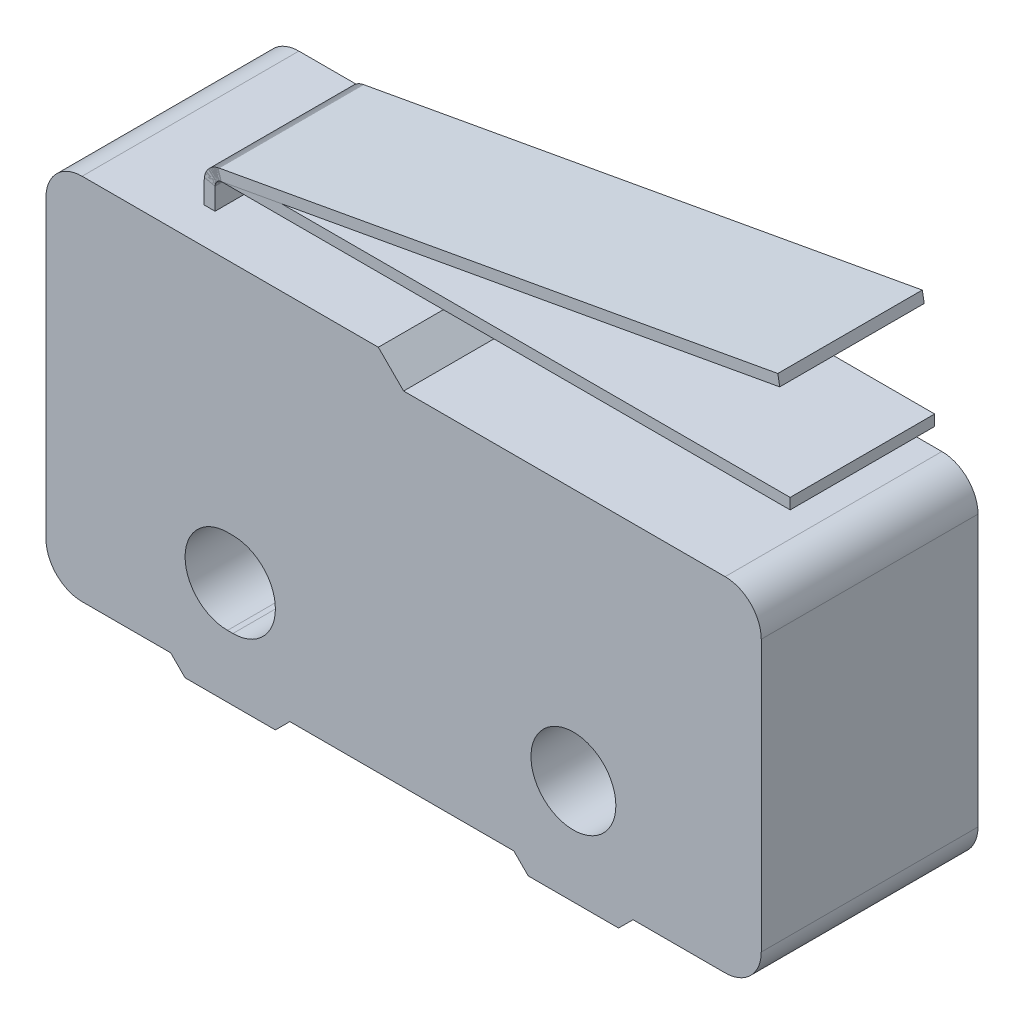
from build123d import *

# Parameters (mm, degrees)
SKETCH1_R           = 1.175
BOSS_EXTRUDE1_DEPTH = 3
FILLET1_R           = 1
BOSS_EXTRUDE3_DEPTH = 2
BOSS_EXTRUDE4_DEPTH = 2


with BuildPart() as part:
    # Sketch1 → Boss-Extrude1 (new body, symmetric)
    with BuildSketch(Plane.XY):
        Polygon((-9.9, -5.1), (-9.9, 5.1), (-0.7, 5.1), (0, 4.4), (9.9, 4.4), (9.9, -5.1), (6.35, -5.1), (5.95, -5.5), (3.45, -5.5), (3.05, -5.1), (-3.15, -5.1), (-3.55, -5.5), (-6.05, -5.5), (-6.45, -5.1), align=None)
        with Locations((4.7, -2.6)):
            Circle(SKETCH1_R, mode=Mode.SUBTRACT)
        with BuildLine():
            Line((-4.875, -1.425), (-4.725, -1.425))
            ThreePointArc((-4.725, -1.425), (-3.55, -2.6), (-4.725, -3.775))
            Line((-4.725, -3.775), (-4.875, -3.775))
            ThreePointArc((-4.875, -3.775), (-6.05, -2.6), (-4.875, -1.425))
        make_face(mode=Mode.SUBTRACT)
    extrude(amount=BOSS_EXTRUDE1_DEPTH, both=True)

    # Fillet1
    fillet1_edges = [part.edges().sort_by_distance(p)[0] for p in [
        (-9.9, -5.1, 0),
        (-9.9, 5.1, 0),
        (9.9, 4.4, 0),
        (9.9, -5.1, 0),
    ]]
    fillet(fillet1_edges, radius=FILLET1_R)

    # Sketch2 → Boss-Extrude3 (add, symmetric)
    with BuildSketch(Plane.XY):
        with BuildLine():
            Line((-6.52, 5.1), (-6.52, 5.7))
            ThreePointArc((-6.52, 5.7), (-6.373553391, 6.053553391), (-6.02, 6.2))
            Line((-6.02, 6.2), (9.7, 6.2))
            Line((9.7, 6.2), (9.7, 5.9))
            Line((9.7, 5.9), (-6.02, 5.9))
            ThreePointArc((-6.02, 5.9), (-6.161421356, 5.841421356), (-6.22, 5.7))
            Line((-6.22, 5.7), (-6.22, 5.1))
            Line((-6.22, 5.1), (-6.52, 5.1))
        make_face()
    extrude(amount=BOSS_EXTRUDE3_DEPTH, both=True)


with BuildPart() as body_2:
    # Sketch4 → Boss-Extrude4 (new body, symmetric)
    with BuildSketch(Plane.XY):
        with BuildLine():
            Line((-6.52, 5.1), (-6.52, 5.7))
            ThreePointArc((-6.52, 5.7), (-6.403834047, 6.020423819), (-6.109314304, 6.191958286))
            Line((-6.109314304, 6.191958286), (9.357854207, 9))
            Line((9.357854207, 9), (9.411442789, 8.704825028))
            Line((9.411442789, 8.704825028), (-6.055725722, 5.896783314))
            ThreePointArc((-6.055725722, 5.896783314), (-6.173533619, 5.828169528), (-6.22, 5.7))
            Line((-6.22, 5.7), (-6.22, 5.1))
            Line((-6.22, 5.1), (-6.52, 5.1))
        make_face()
    extrude(amount=BOSS_EXTRUDE4_DEPTH, both=True)


solid = Compound([part.part, body_2.part])
